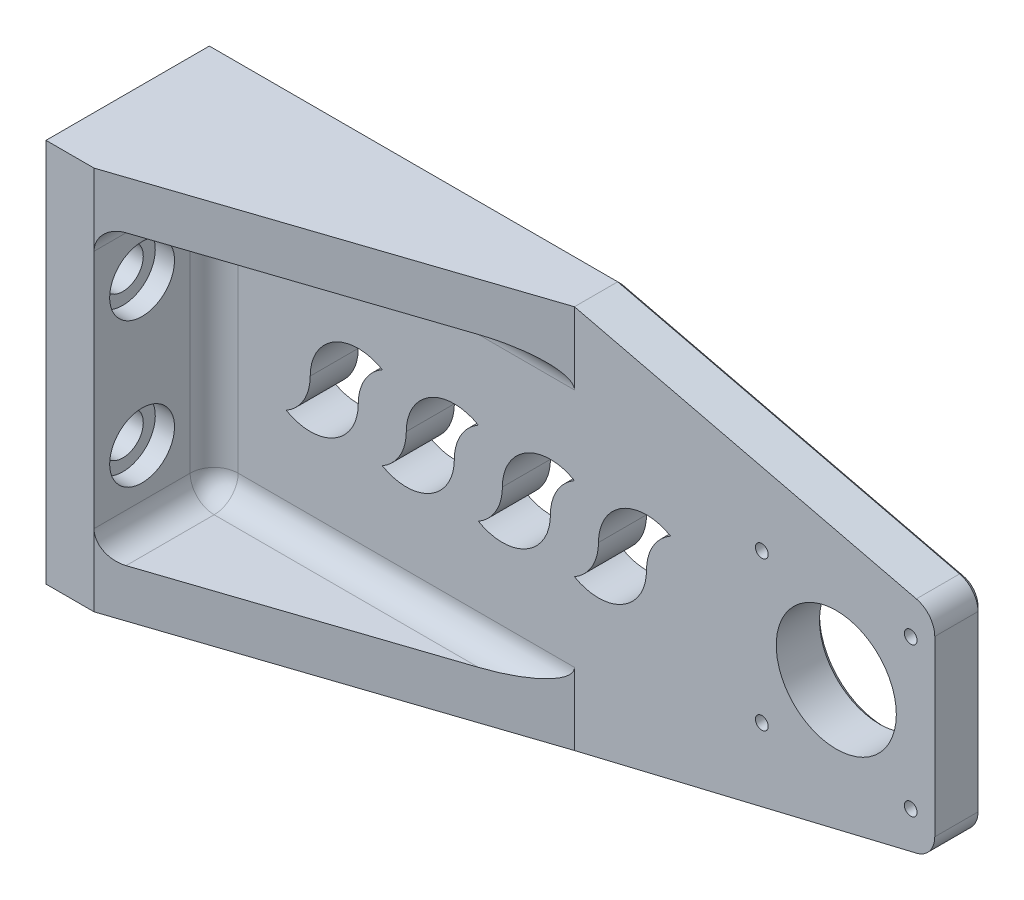
from build123d import *

# Parameters (mm, degrees)
SKETCH1_W           = 160
SKETCH1_H           = 80
BOSS_EXTRUDE1_DEPTH = 10
SKETCH2_R           = 1.325
SKETCH2_R_2         = 12.5
CUT_EXTRUDE1_DEPTH  = 3
CUT_EXTRUDE2_REACH  = 9
SKETCH4_R           = 1.325
SKETCH4_R_2         = 12.5
SKETCH7_W           = 10
SKETCH7_H           = 80
BOSS_EXTRUDE3_DEPTH = 25
BOSS_EXTRUDE4_DEPTH = 10
BOSS_EXTRUDE5_DEPTH = 10
CUT_EXTRUDE3_REACH  = 12
CUT_EXTRUDE4_DEPTH  = 10
FILLET1_R           = 5
SKETCH12_R          = 3.25
CUT_EXTRUDE5_DEPTH  = 4.5
CUT_EXTRUDE6_REACH  = 12
SKETCH13_R          = 4.25
SKETCH14_R          = 6.75
CUT_EXTRUDE7_DEPTH  = 4
FILLET2_R           = 5
CHAMFER2_SIZE       = 1


with BuildPart() as part:
    # Sketch1 → Boss-Extrude1 (new body)
    with BuildSketch(Plane.XY):
        Rectangle(SKETCH1_W, SKETCH1_H)
    extrude(amount=BOSS_EXTRUDE1_DEPTH)

    # Sketch2 → Cut-Extrude1 (cut)
    with BuildSketch(Plane.XY.offset(10)):
        with Locations((44, 15.5)):
            Circle(SKETCH2_R)
        with Locations((75, 15.5)):
            Circle(SKETCH2_R)
        with Locations((44, -15.5)):
            Circle(SKETCH2_R)
        with Locations((75, -15.5)):
            Circle(SKETCH2_R)
        with Locations((59.5, 0)):
            Circle(SKETCH2_R_2)
    extrude(amount=-CUT_EXTRUDE1_DEPTH, mode=Mode.SUBTRACT)

    # Sketch4 → Cut-Extrude2 (cut, up to next)
    with BuildSketch(Plane.XY.offset(7), mode=Mode.PRIVATE) as cut_extrude2_sk1:
        with Locations((75, -15.5)):
            Circle(SKETCH4_R)
    cut_extrude2_tool1 = extrude(cut_extrude2_sk1.sketch, amount=-CUT_EXTRUDE2_REACH, mode=Mode.PRIVATE) & part.part
    add(cut_extrude2_tool1.solids().sort_by_distance((75, -15.5, 7))[0], mode=Mode.SUBTRACT)
    # Sketch4 → Cut-Extrude2 (cut, up to next)
    with BuildSketch(Plane.XY.offset(7), mode=Mode.PRIVATE) as cut_extrude2_sk2:
        with Locations((44, -15.5)):
            Circle(SKETCH4_R)
    cut_extrude2_tool2 = extrude(cut_extrude2_sk2.sketch, amount=-CUT_EXTRUDE2_REACH, mode=Mode.PRIVATE) & part.part
    add(cut_extrude2_tool2.solids().sort_by_distance((44, -15.5, 7))[0], mode=Mode.SUBTRACT)
    # Sketch4 → Cut-Extrude2 (cut, up to next)
    with BuildSketch(Plane.XY.offset(7), mode=Mode.PRIVATE) as cut_extrude2_sk3:
        with Locations((75, 15.5)):
            Circle(SKETCH4_R)
    cut_extrude2_tool3 = extrude(cut_extrude2_sk3.sketch, amount=-CUT_EXTRUDE2_REACH, mode=Mode.PRIVATE) & part.part
    add(cut_extrude2_tool3.solids().sort_by_distance((75, 15.5, 7))[0], mode=Mode.SUBTRACT)
    # Sketch4 → Cut-Extrude2 (cut, up to next)
    with BuildSketch(Plane.XY.offset(7), mode=Mode.PRIVATE) as cut_extrude2_sk4:
        with Locations((44, 15.5)):
            Circle(SKETCH4_R)
    cut_extrude2_tool4 = extrude(cut_extrude2_sk4.sketch, amount=-CUT_EXTRUDE2_REACH, mode=Mode.PRIVATE) & part.part
    add(cut_extrude2_tool4.solids().sort_by_distance((44, 15.5, 7))[0], mode=Mode.SUBTRACT)
    # Sketch4 → Cut-Extrude2 (cut, up to next)
    with BuildSketch(Plane.XY.offset(7), mode=Mode.PRIVATE) as cut_extrude2_sk5:
        with Locations((59.5, 0)):
            Circle(SKETCH4_R_2)
    cut_extrude2_tool5 = extrude(cut_extrude2_sk5.sketch, amount=-CUT_EXTRUDE2_REACH, mode=Mode.PRIVATE) & part.part
    add(cut_extrude2_tool5.solids().sort_by_distance((59.5, 0, 7))[0], mode=Mode.SUBTRACT)

    # Sketch7 → Boss-Extrude3 (add)
    with BuildSketch(Plane.XY.offset(10)):
        with Locations((-75, 0)):
            Rectangle(SKETCH7_W, SKETCH7_H)
    extrude(amount=BOSS_EXTRUDE3_DEPTH)

    # Sketch8 → Boss-Extrude4 (add)
    with BuildSketch(Plane(origin=(0, 40, 0), x_dir=(1, 0, 0), z_dir=(0, 1, 0))):
        Polygon((-70, -35), (5, -10), (-70, -10), align=None)
    extrude(amount=-BOSS_EXTRUDE4_DEPTH)

    # Sketch9 → Boss-Extrude5 (add)
    with BuildSketch(Plane.XZ.offset(40)):
        Polygon((-70, 35), (-70, 10), (5, 10), align=None)
    extrude(amount=-BOSS_EXTRUDE5_DEPTH)

    # Sketch10 → Cut-Extrude3 (cut, up to next)
    with BuildSketch(Plane.XY.offset(10), mode=Mode.PRIVATE) as cut_extrude3_sk1:
        with BuildLine():
            ThreePointArc((5, -8.660254038), (15, -8.660254038), (20, 0))
            ThreePointArc((20, 0), (21.339745962, 5), (25, 8.660254038))
            ThreePointArc((25, 8.660254038), (15, 8.660254038), (10, 0))
            ThreePointArc((10, 0), (8.660254038, -5), (5, -8.660254038))
        make_face()
    cut_extrude3_tool1 = extrude(cut_extrude3_sk1.sketch, amount=-CUT_EXTRUDE3_REACH, mode=Mode.PRIVATE) & part.part
    add(cut_extrude3_tool1.solids().sort_by_distance((15, 0, 10))[0], mode=Mode.SUBTRACT)
    # Sketch10 → Cut-Extrude3 (cut, up to next)
    with BuildSketch(Plane.XY.offset(10), mode=Mode.PRIVATE) as cut_extrude3_sk2:
        with BuildLine():
            ThreePointArc((0, 0), (1.339745962, 5), (5, 8.660254038))
            ThreePointArc((5, 8.660254038), (-5, 8.660254038), (-10, 0))
            ThreePointArc((-10, 0), (-11.339745962, -5), (-15, -8.660254038))
            ThreePointArc((-15, -8.660254038), (-5, -8.660254038), (0, 0))
        make_face()
    cut_extrude3_tool2 = extrude(cut_extrude3_sk2.sketch, amount=-CUT_EXTRUDE3_REACH, mode=Mode.PRIVATE) & part.part
    add(cut_extrude3_tool2.solids().sort_by_distance((-5, 0, 10))[0], mode=Mode.SUBTRACT)
    # Sketch10 → Cut-Extrude3 (cut, up to next)
    with BuildSketch(Plane.XY.offset(10), mode=Mode.PRIVATE) as cut_extrude3_sk3:
        with BuildLine():
            ThreePointArc((-20, 0), (-18.660254038, 5), (-15, 8.660254038))
            ThreePointArc((-15, 8.660254038), (-25, 8.660254038), (-30, 0))
            ThreePointArc((-30, 0), (-31.339745962, -5), (-35, -8.660254038))
            ThreePointArc((-35, -8.660254038), (-25, -8.660254038), (-20, 0))
        make_face()
    cut_extrude3_tool3 = extrude(cut_extrude3_sk3.sketch, amount=-CUT_EXTRUDE3_REACH, mode=Mode.PRIVATE) & part.part
    add(cut_extrude3_tool3.solids().sort_by_distance((-25, 0, 10))[0], mode=Mode.SUBTRACT)
    # Sketch10 → Cut-Extrude3 (cut, up to next)
    with BuildSketch(Plane.XY.offset(10), mode=Mode.PRIVATE) as cut_extrude3_sk4:
        with BuildLine():
            ThreePointArc((-40, 0), (-38.660254038, 5), (-35, 8.660254038))
            ThreePointArc((-35, 8.660254038), (-45, 8.660254038), (-50, 0))
            ThreePointArc((-50, 0), (-51.339745962, -5), (-55, -8.660254038))
            ThreePointArc((-55, -8.660254038), (-45, -8.660254038), (-40, 0))
        make_face()
    cut_extrude3_tool4 = extrude(cut_extrude3_sk4.sketch, amount=-CUT_EXTRUDE3_REACH, mode=Mode.PRIVATE) & part.part
    add(cut_extrude3_tool4.solids().sort_by_distance((-45, 0, 10))[0], mode=Mode.SUBTRACT)

    # Sketch11 → Cut-Extrude4 (cut)
    with BuildSketch(Plane.XY.offset(10)):
        Polygon((80, 22), (5, 40), (80, 40), align=None)
        Polygon((80, -40), (80, -22), (5, -40), align=None)
    extrude(amount=-CUT_EXTRUDE4_DEPTH, mode=Mode.SUBTRACT)

    # Fillet1
    fillet1_edges = [part.edges().sort_by_distance(p)[0] for p in [
        (-70, 30, 22.5),
        (-32.5, 30, 10),
        (-70, 0, 10),
        (-32.5, -30, 10),
        (-70, -30, 22.5),
    ]]
    fillet(fillet1_edges, radius=FILLET1_R)

    # Sketch12 → Cut-Extrude5 (cut)
    with BuildSketch(Plane(origin=(0, 0, 0), x_dir=(-1, 0, 0), z_dir=(0, 0, -1))):
        with Locations((-75, 15.5)):
            Circle(SKETCH12_R)
        with Locations((-44, 15.5)):
            Circle(SKETCH12_R)
        with Locations((-44, -15.5)):
            Circle(SKETCH12_R)
        with Locations((-75, -15.5)):
            Circle(SKETCH12_R)
    extrude(amount=-CUT_EXTRUDE5_DEPTH, mode=Mode.SUBTRACT)

    # Sketch13 → Cut-Extrude6 (cut, up to next)
    with BuildSketch(Plane(origin=(-70, 0, 0), x_dir=(0, 0, -1), z_dir=(1, 0, 0)), mode=Mode.PRIVATE) as cut_extrude6_sk1:
        with Locations((-25, 15)):
            Circle(SKETCH13_R)
    cut_extrude6_tool1 = extrude(cut_extrude6_sk1.sketch, amount=-CUT_EXTRUDE6_REACH, mode=Mode.PRIVATE) & part.part
    add(cut_extrude6_tool1.solids().sort_by_distance((-70, 15, 25))[0], mode=Mode.SUBTRACT)
    # Sketch13 → Cut-Extrude6 (cut, up to next)
    with BuildSketch(Plane(origin=(-70, 0, 0), x_dir=(0, 0, -1), z_dir=(1, 0, 0)), mode=Mode.PRIVATE) as cut_extrude6_sk2:
        with Locations((-25, -15)):
            Circle(SKETCH13_R)
    cut_extrude6_tool2 = extrude(cut_extrude6_sk2.sketch, amount=-CUT_EXTRUDE6_REACH, mode=Mode.PRIVATE) & part.part
    add(cut_extrude6_tool2.solids().sort_by_distance((-70, -15, 25))[0], mode=Mode.SUBTRACT)

    # Sketch14 → Cut-Extrude7 (cut)
    with BuildSketch(Plane(origin=(-70, 0, 0), x_dir=(0, 0, -1), z_dir=(1, 0, 0))):
        with Locations((-25, 15)):
            Circle(SKETCH14_R)
        with Locations((-25, -15)):
            Circle(SKETCH14_R)
    extrude(amount=-CUT_EXTRUDE7_DEPTH, mode=Mode.SUBTRACT)

    # Fillet2
    fillet2_edges = [part.edges().sort_by_distance(p)[0] for p in [
        (80, 22, 5),
        (80, -22, 5),
    ]]
    fillet(fillet2_edges, radius=FILLET2_R)

    # Chamfer2
    chamfer2_edges = [part.edges().sort_by_distance(p)[0] for p in [
        (-37.5, 40, 0),
        (40.583432381, 31.459976229, 0),
        (40.583432381, -31.459976229, 0),
        (80, 0, 0),
        (78.926469394, 21.153631895, 0),
        (78.926469394, -21.153631895, 0),
        (47, 0, 0),
        (-37.5, -40, 0),
        (-80, 0, 0),
    ]]
    chamfer(chamfer2_edges, length=CHAMFER2_SIZE)


solid = part.part
